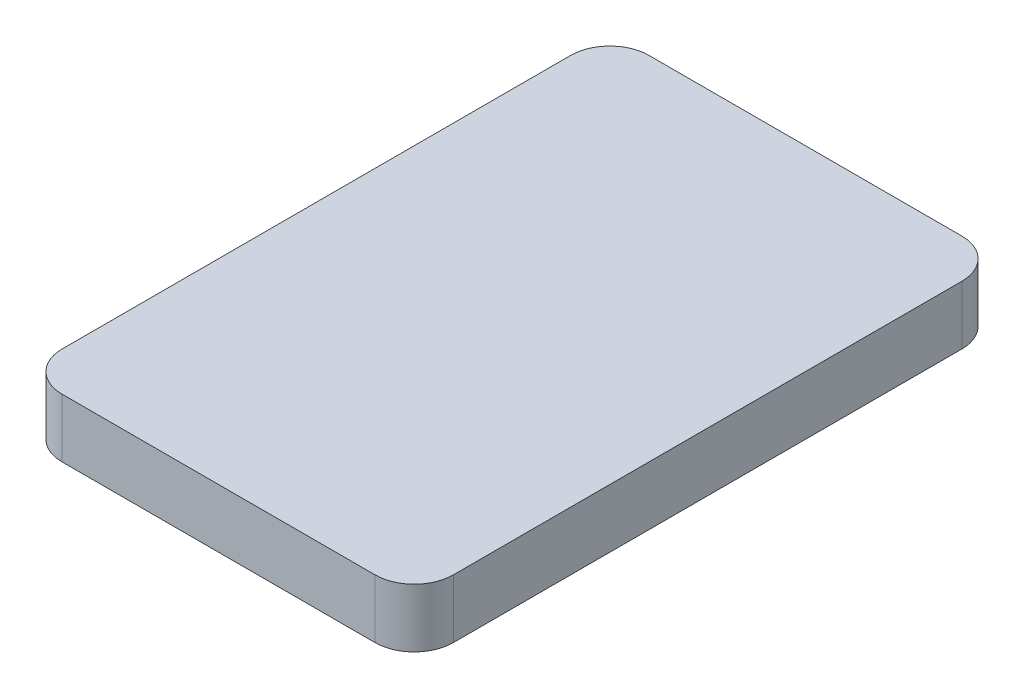
from build123d import *

# Parameters (mm, degrees)
BOSS_EXTRUDE1_DEPTH = 3


with BuildPart() as part:
    # Sketch1 → Boss-Extrude1 (new body)
    with BuildSketch(Plane(origin=(0, 0, 0), x_dir=(1, 0, 0), z_dir=(0, 1, 0))):
        with BuildLine():
            Line((-8, 15), (8, 15))
            ThreePointArc((8, 15), (9.414213562, 14.414213562), (10, 13))
            Line((10, 13), (10, -13))
            ThreePointArc((10, -13), (9.414213562, -14.414213562), (8, -15))
            Line((8, -15), (-8, -15))
            ThreePointArc((-8, -15), (-9.414213562, -14.414213562), (-10, -13))
            Line((-10, -13), (-10, 13))
            ThreePointArc((-10, 13), (-9.414213562, 14.414213562), (-8, 15))
        make_face()
    extrude(amount=BOSS_EXTRUDE1_DEPTH)


solid = part.part
